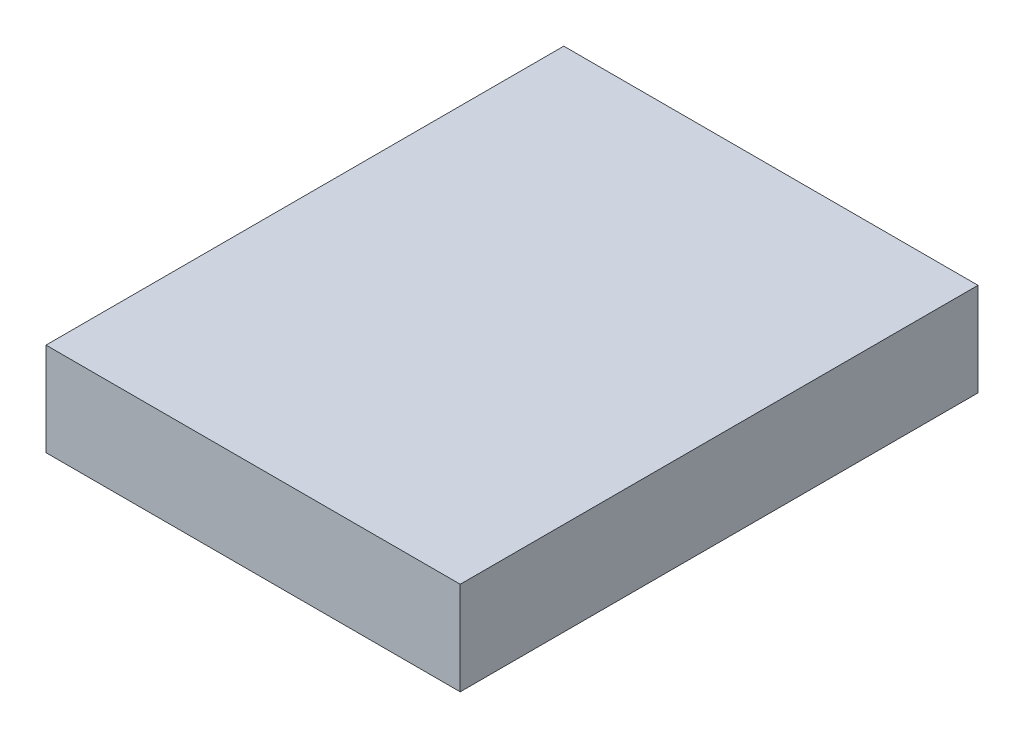
from build123d import *

# Parameters (mm, degrees)
SKETCH1_W           = 8
SKETCH1_H           = 10
BOSS_EXTRUDE1_DEPTH = 1.8


with BuildPart() as part:
    # Sketch1 → Boss-Extrude1 (new body)
    with BuildSketch(Plane(origin=(0, 0, 0), x_dir=(1, 0, 0), z_dir=(0, 1, 0))):
        Rectangle(SKETCH1_W, SKETCH1_H)
    extrude(amount=BOSS_EXTRUDE1_DEPTH)


solid = part.part
